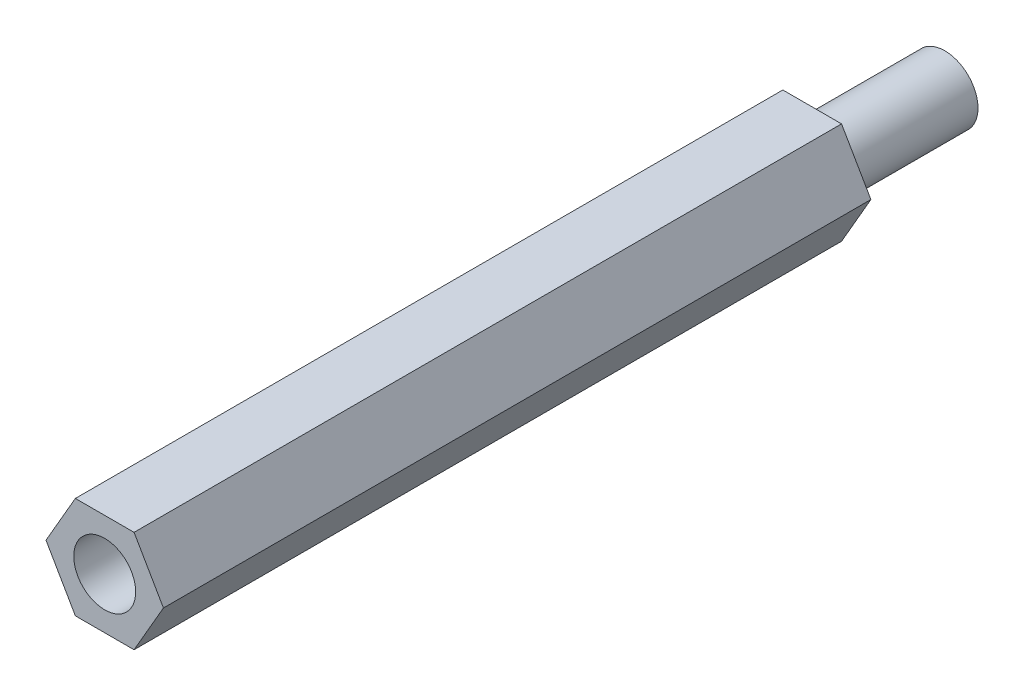
from build123d import *

# Parameters (mm, degrees)
SKETCH_1_R      = 1.4
EXTRUDE_1_DEPTH = 32
SKETCH_2_R      = 1.5
EXTRUDE_2_DEPTH = 6


with BuildPart() as part:
    # 草图1 → 凸台-拉伸1 (new body)
    with BuildSketch(Plane.XY):
        Polygon((2.655811238, 0), (1.327905619, 2.3), (-1.327905619, 2.3), (-2.655811238, 0), (-1.327905619, -2.3), (1.327905619, -2.3), align=None)
        Circle(SKETCH_1_R, mode=Mode.SUBTRACT)
    extrude(amount=EXTRUDE_1_DEPTH)

    # 草图2 → 凸台-拉伸2 (add)
    with BuildSketch(Plane(origin=(0, 0, 0), x_dir=(-1, 0, 0), z_dir=(0, 0, -1))):
        Circle(SKETCH_2_R)
    extrude(amount=EXTRUDE_2_DEPTH)


solid = part.part
